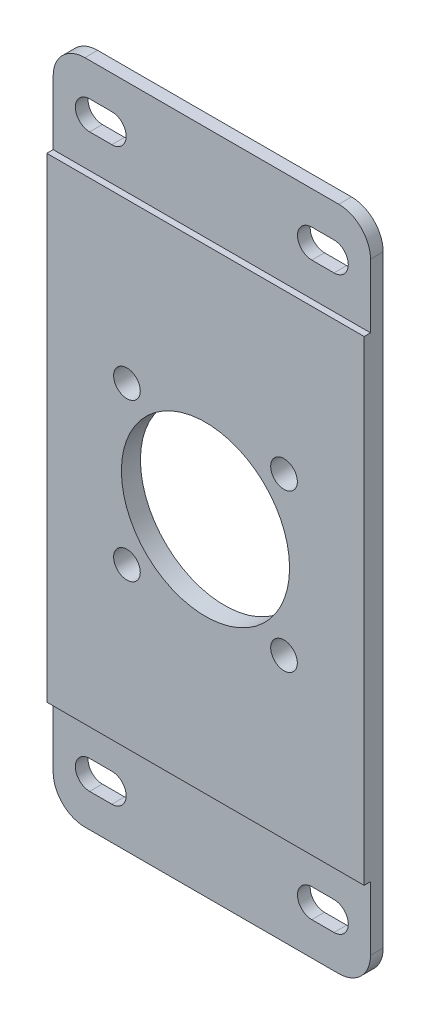
from build123d import *

# Parameters (mm, degrees)
SKETCH_2_W          = 50
SKETCH_2_H          = 105
SKETCH_2_R          = 13.25
SKETCH_2_R_2        = 2.1
EXTRUDE_1_DEPTH     = 3
SKETCH_3_W          = 50
SKETCH_3_H          = 15.05
CUT_EXTRUDE_1_DEPTH = 1
FILLET_1_R          = 5


with BuildPart() as part:
    # ｽｹｯﾁ2 → ﾎﾞｽ - 押し出し1 (new body)
    with BuildSketch(Plane.XY):
        with Locations((25, 52.5)):
            Rectangle(SKETCH_2_W, SKETCH_2_H)
        with Locations((25, 52.5)):
            Circle(SKETCH_2_R, mode=Mode.SUBTRACT)
        with Locations((37.374368671, 64.874368671)):
            Circle(SKETCH_2_R_2, mode=Mode.SUBTRACT)
        with Locations((12.625631329, 64.874368671)):
            Circle(SKETCH_2_R_2, mode=Mode.SUBTRACT)
        with Locations((37.374368671, 40.125631329)):
            Circle(SKETCH_2_R_2, mode=Mode.SUBTRACT)
        with Locations((12.625631329, 40.125631329)):
            Circle(SKETCH_2_R_2, mode=Mode.SUBTRACT)
        with BuildLine():
            Line((5.75, 9.75), (9.25, 9.75))
            ThreePointArc((9.25, 9.75), (11.5, 7.5), (9.25, 5.25))
            Line((9.25, 5.25), (5.75, 5.25))
            ThreePointArc((5.75, 5.25), (3.5, 7.5), (5.75, 9.75))
        make_face(mode=Mode.SUBTRACT)
        with BuildLine():
            Line((40.750000202, 9.75), (44.250000202, 9.75))
            ThreePointArc((44.250000202, 9.75), (46.500000202, 7.5), (44.250000202, 5.25))
            Line((44.250000202, 5.25), (40.750000202, 5.25))
            ThreePointArc((40.750000202, 5.25), (38.500000202, 7.5), (40.750000202, 9.75))
        make_face(mode=Mode.SUBTRACT)
        with BuildLine():
            Line((40.750000101, 99.75), (44.250000101, 99.75))
            ThreePointArc((44.250000101, 99.75), (46.500000101, 97.5), (44.250000101, 95.25))
            Line((44.250000101, 95.25), (40.750000101, 95.25))
            ThreePointArc((40.750000101, 95.25), (38.500000101, 97.5), (40.750000101, 99.75))
        make_face(mode=Mode.SUBTRACT)
        with BuildLine():
            Line((5.749999899, 99.75), (9.249999899, 99.75))
            ThreePointArc((9.249999899, 99.75), (11.499999899, 97.5), (9.249999899, 95.25))
            Line((9.249999899, 95.25), (5.749999899, 95.25))
            ThreePointArc((5.749999899, 95.25), (3.499999899, 97.5), (5.749999899, 99.75))
        make_face(mode=Mode.SUBTRACT)
    extrude(amount=EXTRUDE_1_DEPTH)

    # ｽｹｯﾁ3 → ｶｯﾄ - 押し出し1 (cut)
    with BuildSketch(Plane.XY.offset(3)):
        with Locations((25, 97.475)):
            Rectangle(SKETCH_3_W, SKETCH_3_H)
        with Locations((25, 7.525)):
            Rectangle(SKETCH_3_W, SKETCH_3_H)
    extrude(amount=-CUT_EXTRUDE_1_DEPTH, mode=Mode.SUBTRACT)

    # ﾌｨﾚｯﾄ1
    fillet_1_edges = [part.edges().sort_by_distance(p)[0] for p in [
        (0, 105, 1),
        (50, 105, 1),
        (50, 0, 1),
        (0, 0, 1),
    ]]
    fillet(fillet_1_edges, radius=FILLET_1_R)


solid = part.part
